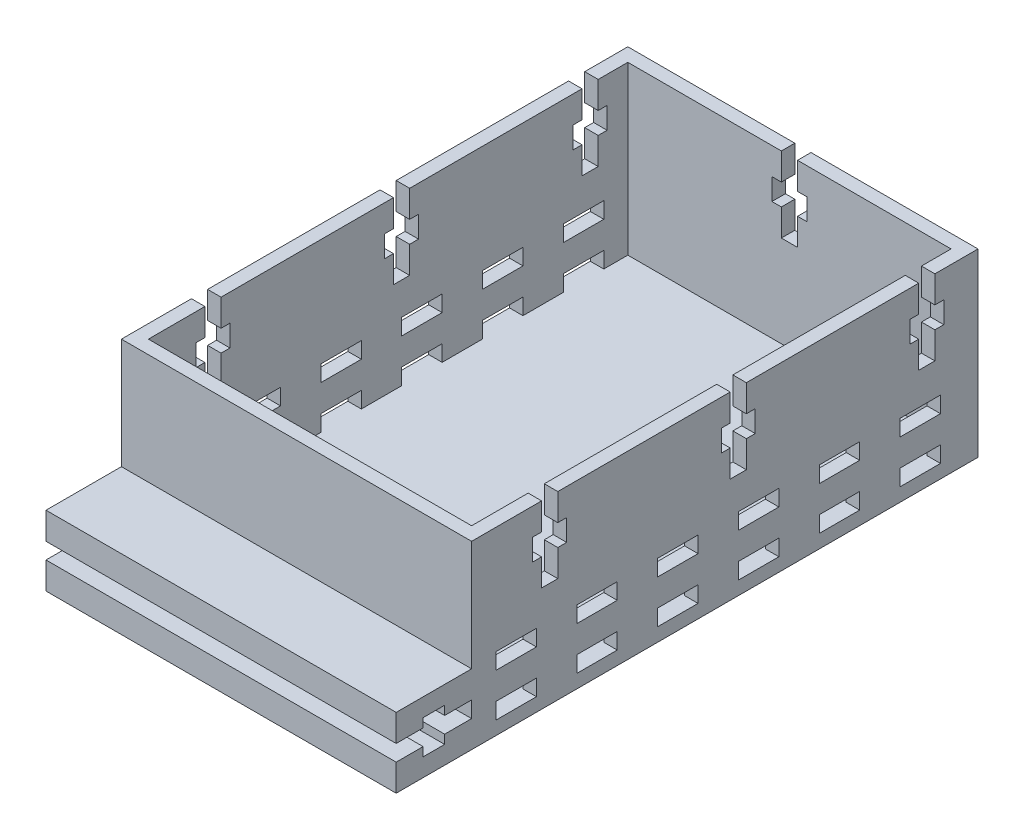
from build123d import *

# Parameters (mm, degrees)
SKETCH1_W                 = 60
SKETCH1_H                 = 89
BOSS_EXTRUDE1_DEPTH       = 2.5
SKETCH3_W                 = 65
SKETCH3_H                 = 94
SKETCH3_W_2               = 60
SKETCH3_H_2               = 89
BOSS_EXTRUDE2_DEPTH       = 33.5
SKETCH5_W                 = 7.5
SKETCH5_H                 = 3
CUT_EXTRUDE1_DEPTH        = 33.5
LPATTERN1_COUNT           = 6
LPATTERN1_PITCH           = 15
LPATTERN2_COUNT           = 2
LPATTERN2_PITCH           = 8
LPATTERN2_COPY_1_SKETCH_W = 7.5
LPATTERN2_COPY_1_SKETCH_H = 3
LPATTERN2_COPY_1_DEPTH    = 33.5
LPATTERN2_COPY_2_SKETCH_W = 7.5
LPATTERN2_COPY_2_SKETCH_H = 3
LPATTERN2_COPY_2_DEPTH    = 33.5
LPATTERN2_COPY_3_SKETCH_W = 7.5
LPATTERN2_COPY_3_SKETCH_H = 3
LPATTERN2_COPY_3_DEPTH    = 33.5
LPATTERN2_COPY_4_SKETCH_W = 7.5
LPATTERN2_COPY_4_SKETCH_H = 3
LPATTERN2_COPY_4_DEPTH    = 33.5
LPATTERN2_COPY_5_SKETCH_W = 7.5
LPATTERN2_COPY_5_SKETCH_H = 3
LPATTERN2_COPY_5_DEPTH    = 33.5
SKETCH6_W                 = 65
SKETCH6_H                 = 14
BOSS_EXTRUDE3_DEPTH       = 13
CUT_EXTRUDE2_DEPTH        = 33.5
CUT_EXTRUDE2_DEPTH_BACK   = 33.5
CUT_EXTRUDE3_DEPTH        = 33.5
LPATTERN3_COUNT           = 3
LPATTERN3_PITCH           = 35
CUT_EXTRUDE4_REACH        = 49


with BuildPart() as part:
    # Sketch1 → Boss-Extrude1 (new body)
    with BuildSketch(Plane(origin=(0, 0, 0), x_dir=(1, 0, 0), z_dir=(0, 1, 0))):
        Rectangle(SKETCH1_W, SKETCH1_H)
    extrude(amount=BOSS_EXTRUDE1_DEPTH)

    # Sketch3 → Boss-Extrude2 (add)
    with BuildSketch(Plane(origin=(0, 0, 0), x_dir=(1, 0, 0), z_dir=(0, 1, 0))):
        Rectangle(SKETCH3_W, SKETCH3_H)
        Rectangle(SKETCH3_W_2, SKETCH3_H_2, mode=Mode.SUBTRACT)
    extrude(amount=BOSS_EXTRUDE2_DEPTH)

    # Sketch5 → Cut-Extrude1 (cut, symmetric)
    with BuildSketch(Plane(origin=(0, 0, 0), x_dir=(0, 0, -1), z_dir=(1, 0, 0))):
        with Locations((-38.715113754, 4)):
            Rectangle(SKETCH5_W, SKETCH5_H)
    cut_extrude1 = extrude(amount=CUT_EXTRUDE1_DEPTH, both=True, mode=Mode.SUBTRACT)

    # LPattern1: Cut-Extrude1 ×6
    with Locations(*[(0, 0, -i * LPATTERN1_PITCH) for i in range(1, LPATTERN1_COUNT)]):
        add(cut_extrude1, mode=Mode.SUBTRACT)

    # LPattern2: Cut-Extrude1 ×2
    with Locations(*[(0, i * LPATTERN2_PITCH, 0) for i in range(1, LPATTERN2_COUNT)]):
        add(cut_extrude1, mode=Mode.SUBTRACT)

    # LPattern2 copy 1 sketch → LPattern2 copy 1 (cut, symmetric)
    with BuildSketch(Plane(origin=(0, 8, -15), x_dir=(0, 0, -1), z_dir=(1, 0, 0))):
        with Locations((-38.715113754, 4)):
            Rectangle(LPATTERN2_COPY_1_SKETCH_W, LPATTERN2_COPY_1_SKETCH_H)
    extrude(amount=LPATTERN2_COPY_1_DEPTH, both=True, mode=Mode.SUBTRACT)

    # LPattern2 copy 2 sketch → LPattern2 copy 2 (cut, symmetric)
    with BuildSketch(Plane(origin=(0, 8, -30), x_dir=(0, 0, -1), z_dir=(1, 0, 0))):
        with Locations((-38.715113754, 4)):
            Rectangle(LPATTERN2_COPY_2_SKETCH_W, LPATTERN2_COPY_2_SKETCH_H)
    extrude(amount=LPATTERN2_COPY_2_DEPTH, both=True, mode=Mode.SUBTRACT)

    # LPattern2 copy 3 sketch → LPattern2 copy 3 (cut, symmetric)
    with BuildSketch(Plane(origin=(0, 8, -45), x_dir=(0, 0, -1), z_dir=(1, 0, 0))):
        with Locations((-38.715113754, 4)):
            Rectangle(LPATTERN2_COPY_3_SKETCH_W, LPATTERN2_COPY_3_SKETCH_H)
    extrude(amount=LPATTERN2_COPY_3_DEPTH, both=True, mode=Mode.SUBTRACT)

    # LPattern2 copy 4 sketch → LPattern2 copy 4 (cut, symmetric)
    with BuildSketch(Plane(origin=(0, 8, -60), x_dir=(0, 0, -1), z_dir=(1, 0, 0))):
        with Locations((-38.715113754, 4)):
            Rectangle(LPATTERN2_COPY_4_SKETCH_W, LPATTERN2_COPY_4_SKETCH_H)
    extrude(amount=LPATTERN2_COPY_4_DEPTH, both=True, mode=Mode.SUBTRACT)

    # LPattern2 copy 5 sketch → LPattern2 copy 5 (cut, symmetric)
    with BuildSketch(Plane(origin=(0, 8, -75), x_dir=(0, 0, -1), z_dir=(1, 0, 0))):
        with Locations((-38.715113754, 4)):
            Rectangle(LPATTERN2_COPY_5_SKETCH_W, LPATTERN2_COPY_5_SKETCH_H)
    extrude(amount=LPATTERN2_COPY_5_DEPTH, both=True, mode=Mode.SUBTRACT)

    # Sketch6 → Boss-Extrude3 (add)
    with BuildSketch(Plane(origin=(0, 0, 0), x_dir=(1, 0, 0), z_dir=(0, 1, 0))):
        with Locations((0, -54)):
            Rectangle(SKETCH6_W, SKETCH6_H)
    extrude(amount=BOSS_EXTRUDE3_DEPTH)

    # Sketch7 → Cut-Extrude2 (cut, two sides)
    with BuildSketch(Plane(origin=(0, 0, 0), x_dir=(0, 0, -1), z_dir=(1, 0, 0))) as cut_extrude2_sk:
        Polygon((-61, 8), (-56, 8), (-56, 9.65), (-52, 9.65), (-52, 8), (-47, 8), (-47, 5), (-52, 5), (-52, 3.35), (-56, 3.35), (-56, 5), (-61, 5), align=None)
    extrude(amount=CUT_EXTRUDE2_DEPTH, mode=Mode.SUBTRACT)
    extrude(cut_extrude2_sk.sketch, amount=-CUT_EXTRUDE2_DEPTH_BACK, mode=Mode.SUBTRACT)

    # Sketch11 → Cut-Extrude3 (cut, symmetric)
    with BuildSketch(Plane(origin=(0, 0, 0), x_dir=(0, 0, -1), z_dir=(1, 0, 0))):
        Polygon((39, 33.5), (39, 28.5), (40.65, 28.5), (40.65, 24.5), (39, 24.5), (39, 19.5), (36, 19.5), (36, 24.5), (34.35, 24.5), (34.35, 28.5), (36, 28.5), (36, 33.5), align=None)
    cut_extrude3 = extrude(amount=CUT_EXTRUDE3_DEPTH, both=True, mode=Mode.SUBTRACT)

    # LPattern3: Cut-Extrude3 ×3
    with Locations(*[(0, 0, i * LPATTERN3_PITCH) for i in range(1, LPATTERN3_COUNT)]):
        add(cut_extrude3, mode=Mode.SUBTRACT)

    # Sketch12 → Cut-Extrude4 (cut, up to next)
    with BuildSketch(Plane.XY, mode=Mode.PRIVATE) as cut_extrude4_sk1:
        Polygon((1.5, 33.5), (1.5, 28.5), (3.25, 28.5), (3.25, 24.5), (1.5, 24.5), (1.5, 19.5), (-1.5, 19.5), (-1.5, 24.5), (-3.25, 24.5), (-3.25, 28.5), (-1.5, 28.5), (-1.5, 33.5), align=None)
    cut_extrude4_tool1 = extrude(cut_extrude4_sk1.sketch, amount=-CUT_EXTRUDE4_REACH, mode=Mode.PRIVATE) & part.part
    add(cut_extrude4_tool1.solids().sort_by_distance((0, 26.5, 0))[0], mode=Mode.SUBTRACT)


solid = part.part
